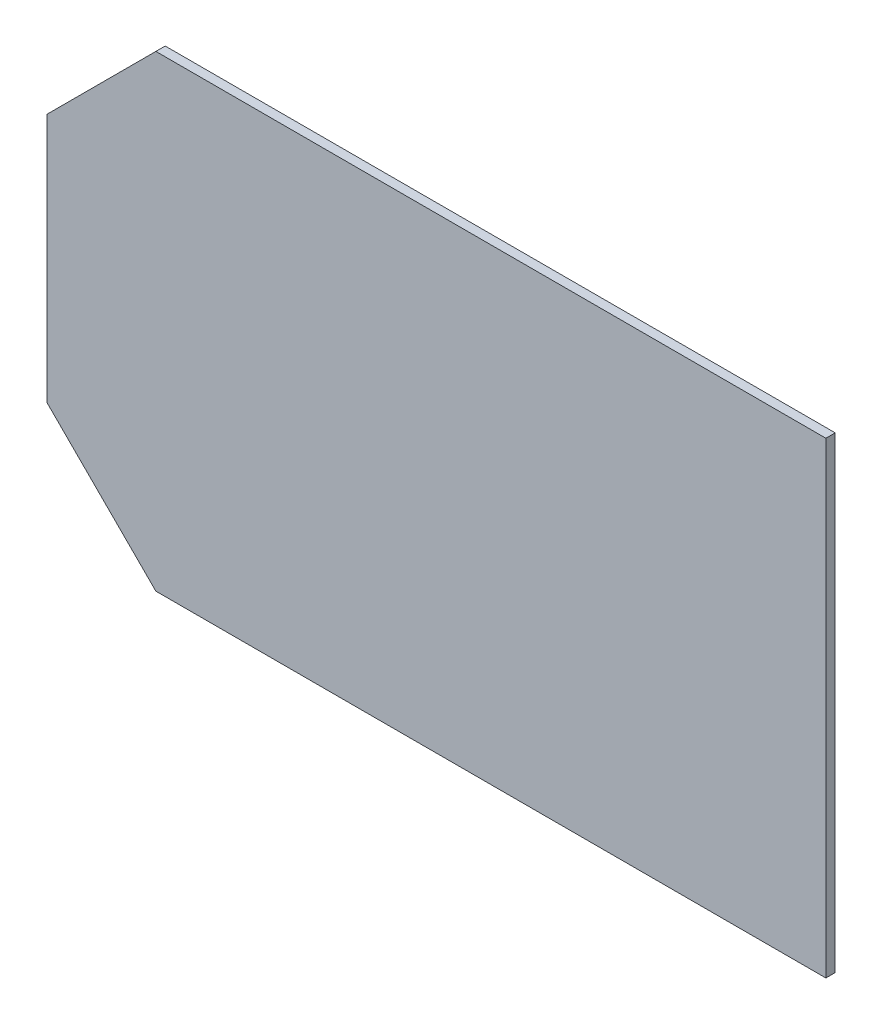
from build123d import *

# Parameters (mm, degrees)
SKETCH1_W           = 250
SKETCH1_H           = 150
BOSS_EXTRUDE1_DEPTH = 3
CHAMFER3_SIZE       = 35


with BuildPart() as part:
    # Sketch1 → Boss-Extrude1 (new body)
    with BuildSketch(Plane.XY):
        Rectangle(SKETCH1_W, SKETCH1_H)
    extrude(amount=BOSS_EXTRUDE1_DEPTH)

    # Chamfer3
    chamfer3_edges = [part.edges().sort_by_distance(p)[0] for p in [
        (-125, -75, 1.5),
        (-125, 75, 1.5),
    ]]
    chamfer(chamfer3_edges, length=CHAMFER3_SIZE)


solid = part.part
